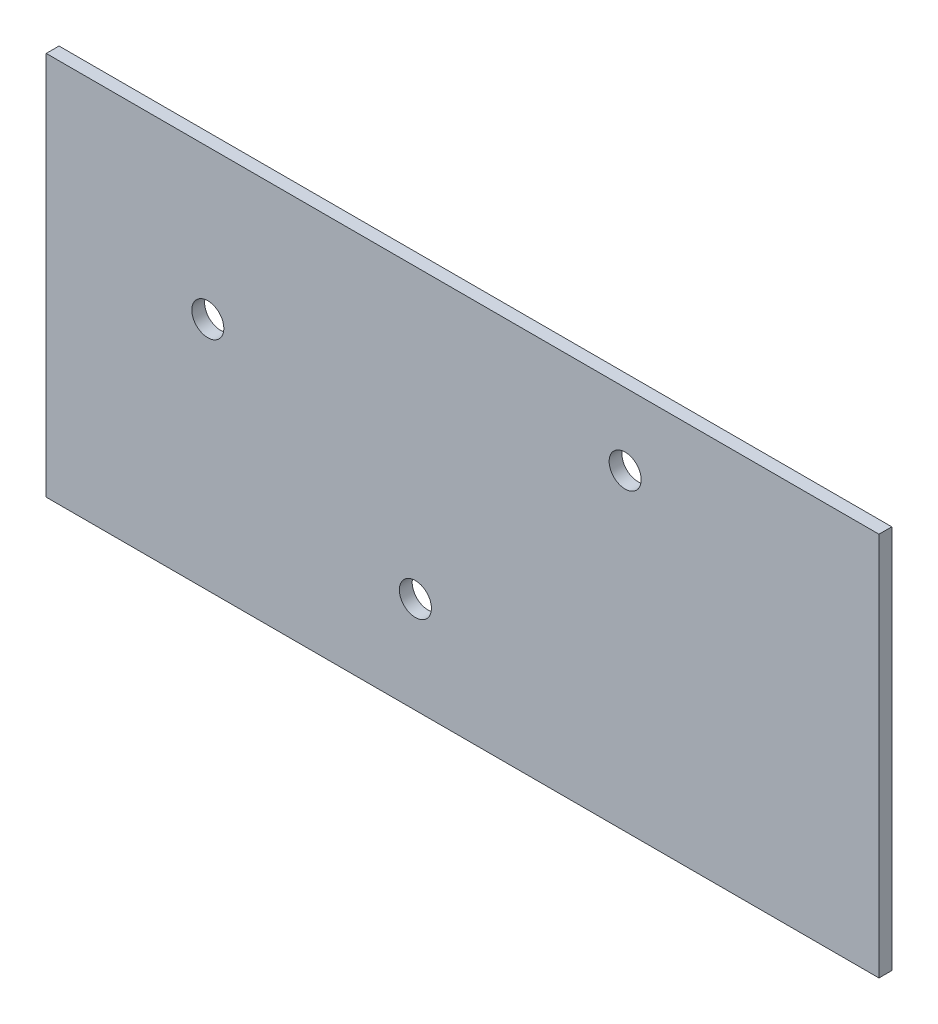
from build123d import *

# Parameters (mm, degrees)
SKETCH1_W                  = 165.1
SKETCH1_H                  = 76.2
BOSS_EXTRUDE1_DEPTH        = 2.54
F_1_4_0_2500_DOWEL_HOLE1_D = 6.35


with BuildPart() as part:
    # Sketch1 → Boss-Extrude1 (new body)
    with BuildSketch(Plane.XY):
        Rectangle(SKETCH1_W, SKETCH1_H)
    extrude(amount=BOSS_EXTRUDE1_DEPTH)

    # 1/4 (0.2500) Dowel Hole1 (through all)
    with Locations(Plane(origin=(-50.512645238, 8.474787733, 2.54), x_dir=(1, 0, 0), z_dir=(0, 0, 1))):
        with Locations((0, 0), (41.154917852, -27.464087264), (82.739905764, 15.386269222)):
            Hole(F_1_4_0_2500_DOWEL_HOLE1_D / 2)


solid = part.part
